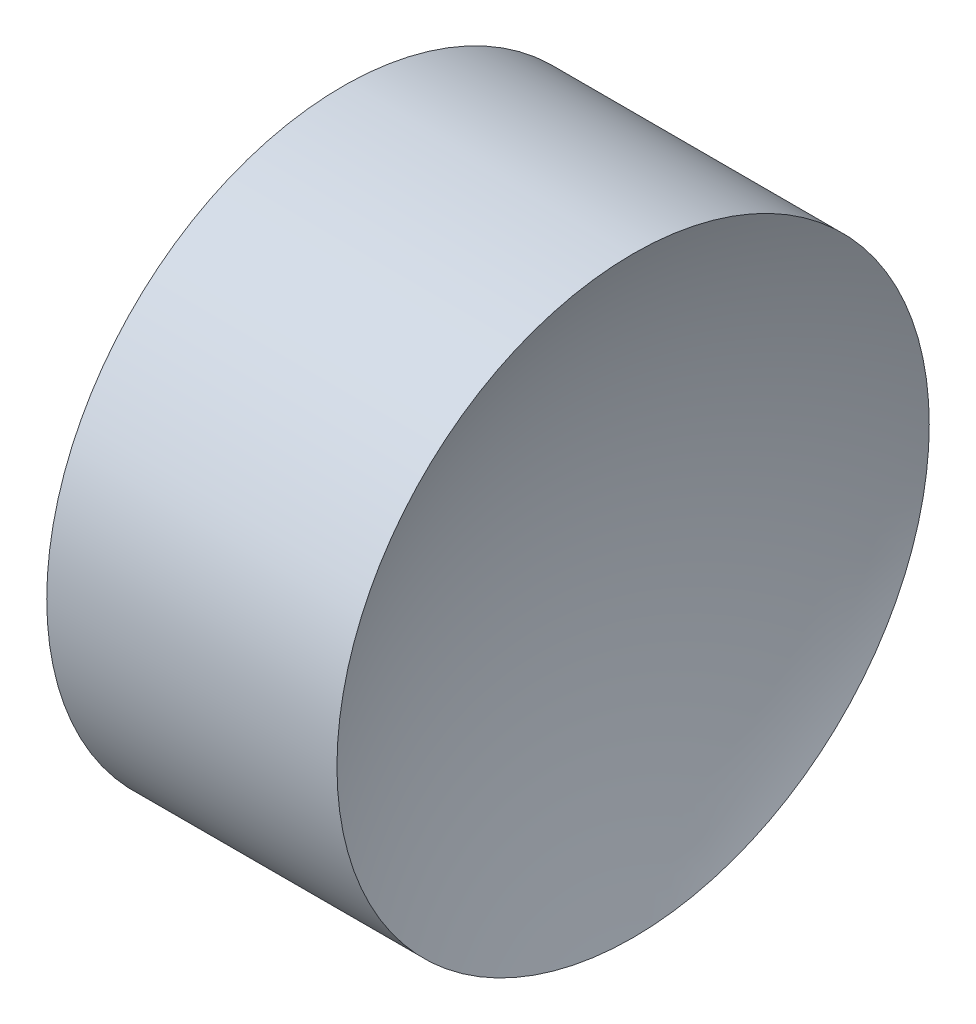
from build123d import *


with BuildPart() as part:
    # 草图1 → 旋转1 (revolve)
    with BuildSketch(Plane.XY):
        with BuildLine():
            Line((11.080595085, 6.515563046), (11.080595085, 8.515563046))
            Line((11.080595085, 8.515563046), (13.040352373, 8.515563046))
            ThreePointArc((13.040352373, 8.515563046), (12.697014033, 7.541645007), (12.580595085, 6.515563046))
            Line((12.580595085, 6.515563046), (11.080595085, 6.515563046))
        make_face()
    revolve(axis=Axis((10.578235961, 6.515563046, 0), (1, 0, 0)))


solid = part.part
